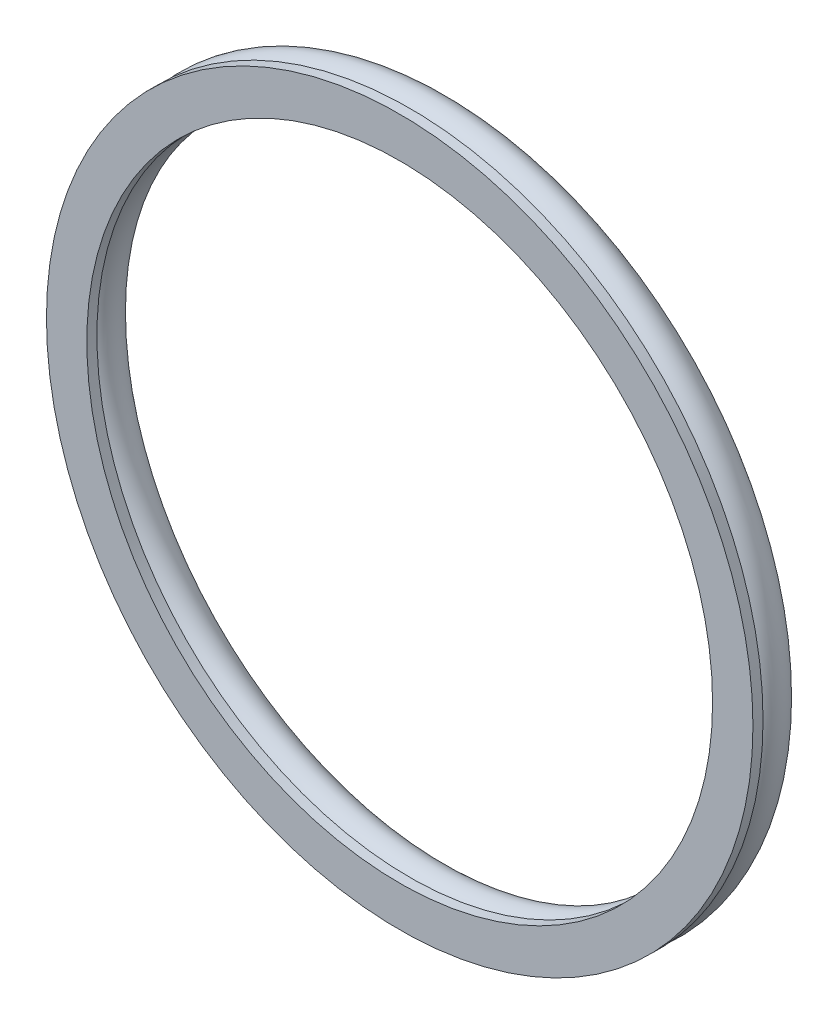
from build123d import *

# Parameters (mm, degrees)
SKETCH3_R           = 10
SKETCH5_R           = 175
SKETCH5_R_2         = 155
BOSS_EXTRUDE1_DEPTH = 5


with BuildPart() as part:
    # Sketch3 → Revolve1 (revolve)
    with BuildSketch(Plane(origin=(0, 0, 0), x_dir=(0, 0, -1), z_dir=(1, 0, 0))):
        with Locations((0, 165)):
            Circle(SKETCH3_R)
    revolve(axis=Axis((0, 0, 0), (0, 0, -1)))


with BuildPart() as body_2:
    # Sketch5 → Boss-Extrude1 (new body)
    with BuildSketch(Plane.XY.offset(10)):
        Circle(SKETCH5_R)
        Circle(SKETCH5_R_2, mode=Mode.SUBTRACT)
    extrude(amount=BOSS_EXTRUDE1_DEPTH)


solid = Compound([part.part, body_2.part])
